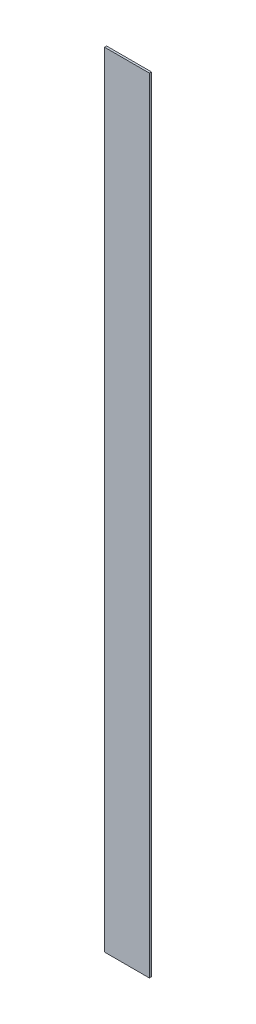
from build123d import *

# Parameters (mm, degrees)
BOSS_EXTRUDE1_DEPTH = 4


with BuildPart() as part:
    # Sketch1 → Boss-Extrude1 (new body)
    with BuildSketch(Plane.XY):
        Polygon((-43, -752), (43, -752), (43, 752), (-38, 752), (-43, 752), align=None)
    extrude(amount=BOSS_EXTRUDE1_DEPTH)


solid = part.part
